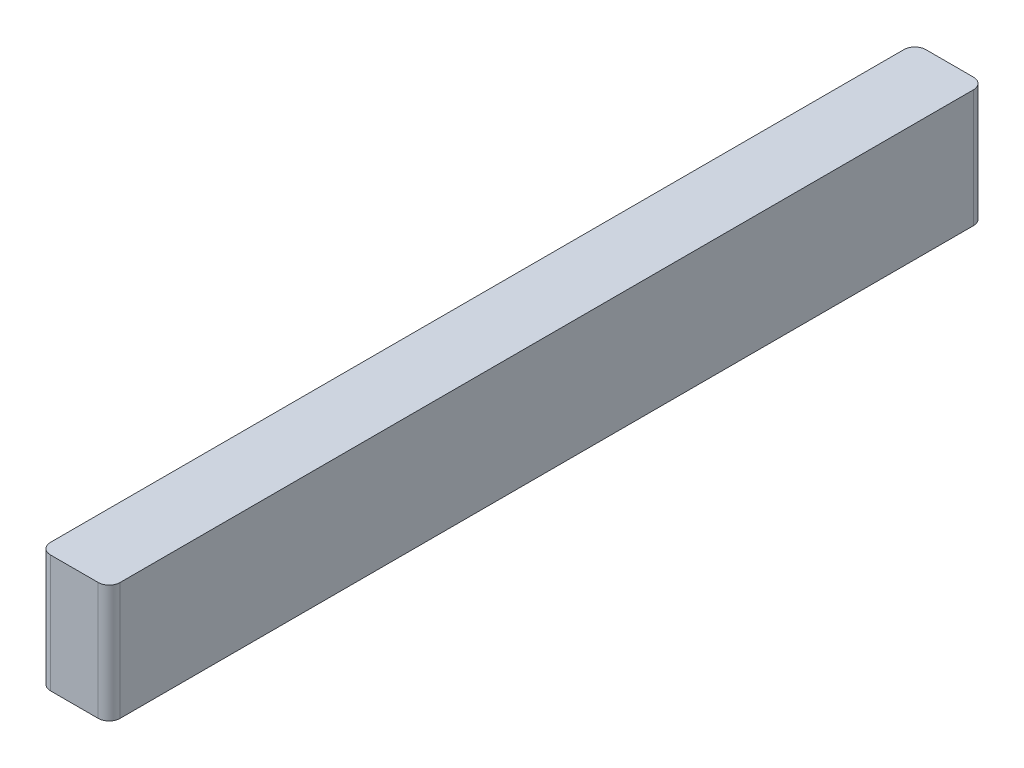
from build123d import *

# Parameters (mm, degrees)
BOSS_EXTRUDE1_DEPTH = 68.326


with BuildPart() as part:
    # Sketch1 → Boss-Extrude1 (new body)
    with BuildSketch(Plane(origin=(0, 0, 0), x_dir=(1, 0, 0), z_dir=(0, 1, 0))):
        with BuildLine():
            Line((6.35, 0), (34.036, 0))
            ThreePointArc((34.036, 0), (38.526128061, 1.859871939), (40.386, 6.35))
            Line((40.386, 6.35), (40.386, 501.65))
            ThreePointArc((40.386, 501.65), (38.526128061, 506.140128061), (34.036, 508))
            Line((34.036, 508), (6.35, 508))
            ThreePointArc((6.35, 508), (1.859871939, 506.140128061), (0, 501.65))
            Line((0, 501.65), (0, 6.35))
            ThreePointArc((0, 6.35), (1.859871939, 1.859871939), (6.35, 0))
        make_face()
    extrude(amount=BOSS_EXTRUDE1_DEPTH)


solid = part.part
